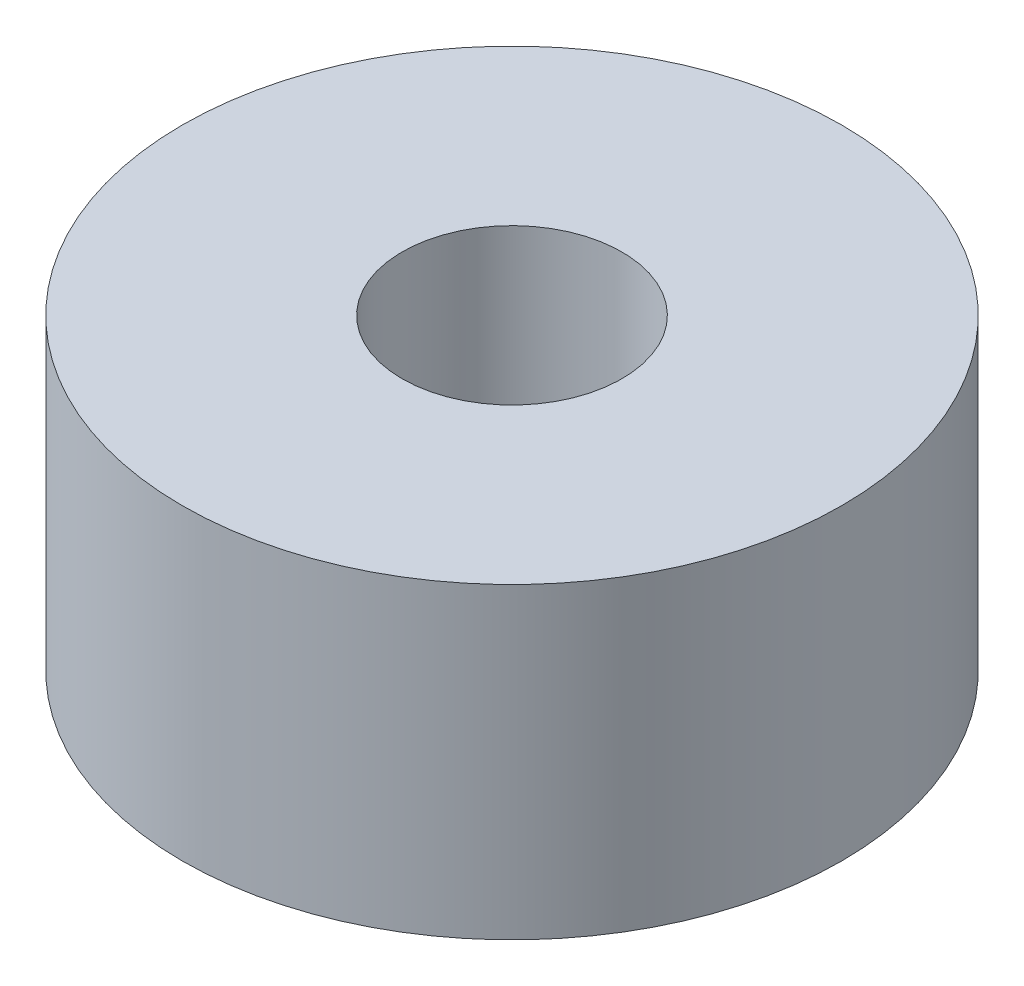
from build123d import *

# Parameters (mm, degrees)
SKETCH1_R           = 15
SKETCH1_R_2         = 5
BOSS_EXTRUDE1_DEPTH = 14


with BuildPart() as part:
    # Sketch1 → Boss-Extrude1 (new body)
    with BuildSketch(Plane(origin=(0, 0, 0), x_dir=(1, 0, 0), z_dir=(0, 1, 0))):
        Circle(SKETCH1_R)
        Circle(SKETCH1_R_2, mode=Mode.SUBTRACT)
    extrude(amount=BOSS_EXTRUDE1_DEPTH)


solid = part.part
